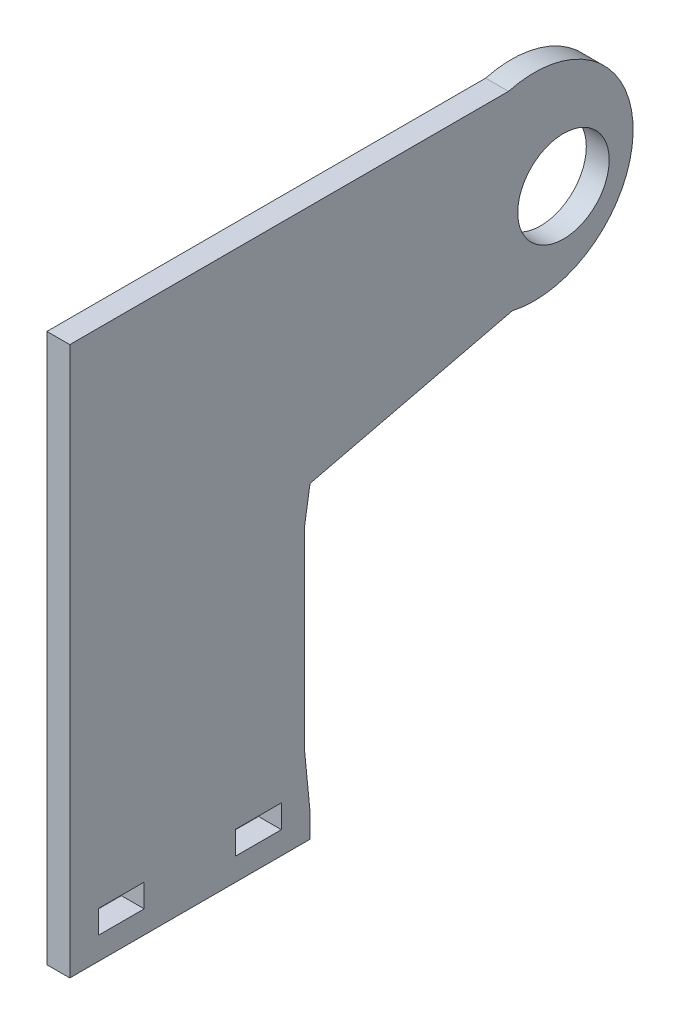
from build123d import *

# Parameters (mm, degrees)
BOSS_EXTRUDE1_DEPTH = 3.175
SKETCH3_R           = 6.35
CUT_EXTRUDE2_DEPTH  = 4.175
CUT_EXTRUDE4_DEPTH  = 4.175
SKETCH4_W           = 6.35
SKETCH4_H           = 3.2258
CUT_EXTRUDE3_DEPTH  = 4.175


with BuildPart() as part:
    # Sketch1 → Boss-Extrude1 (new body)
    with BuildSketch(Plane(origin=(0, 0, 0), x_dir=(0, 0, -1), z_dir=(1, 0, 0))):
        with BuildLine():
            Line((20.308664328, 40.617328656), (43.157786531, 40.617328656))
            ThreePointArc((43.157786531, 40.617328656), (60.466141811, 27.624512399), (43.692194932, 13.948725661))
            Line((43.692194932, 13.948725661), (15.586038544, 7.228441393))
            Line((15.586038544, 7.228441393), (15.586038544, -35.582671344))
            Line((15.586038544, -35.582671344), (-17.791335672, -35.582671344))
            Line((-17.791335672, -35.582671344), (-17.791335672, 40.617328656))
            Line((-17.791335672, 40.617328656), (20.308664328, 40.617328656))
        make_face()
    extrude(amount=BOSS_EXTRUDE1_DEPTH)

    # Sketch3 → Cut-Extrude2 (cut, through all)
    with BuildSketch(Plane(origin=(3.175, 0, 0), x_dir=(0, 0, -1), z_dir=(1, 0, 0))):
        with Locations((50.788664328, 25.377328656)):
            Circle(SKETCH3_R)
    extrude(amount=-CUT_EXTRUDE2_DEPTH, mode=Mode.SUBTRACT)

    # Sketch5 → Cut-Extrude4 (cut, through all)
    with BuildSketch(Plane.ZY):
        Polygon((-15.586038544, 7.228441393), (-14.846971332, 2.578544694), (-14.846971332, -24.724280649), (-15.586038544, -32.273448946), align=None)
    extrude(amount=-CUT_EXTRUDE4_DEPTH, mode=Mode.SUBTRACT)

    # Sketch4 → Cut-Extrude3 (cut, through all)
    with BuildSketch(Plane(origin=(3.175, 0, 0), x_dir=(0, 0, -1), z_dir=(1, 0, 0))):
        with Locations((-10.627648564, -30.820171344)):
            Rectangle(SKETCH4_W, SKETCH4_H)
        with Locations((8.422351436, -30.820171344)):
            Rectangle(SKETCH4_W, SKETCH4_H)
    extrude(amount=-CUT_EXTRUDE3_DEPTH, mode=Mode.SUBTRACT)


solid = part.part
